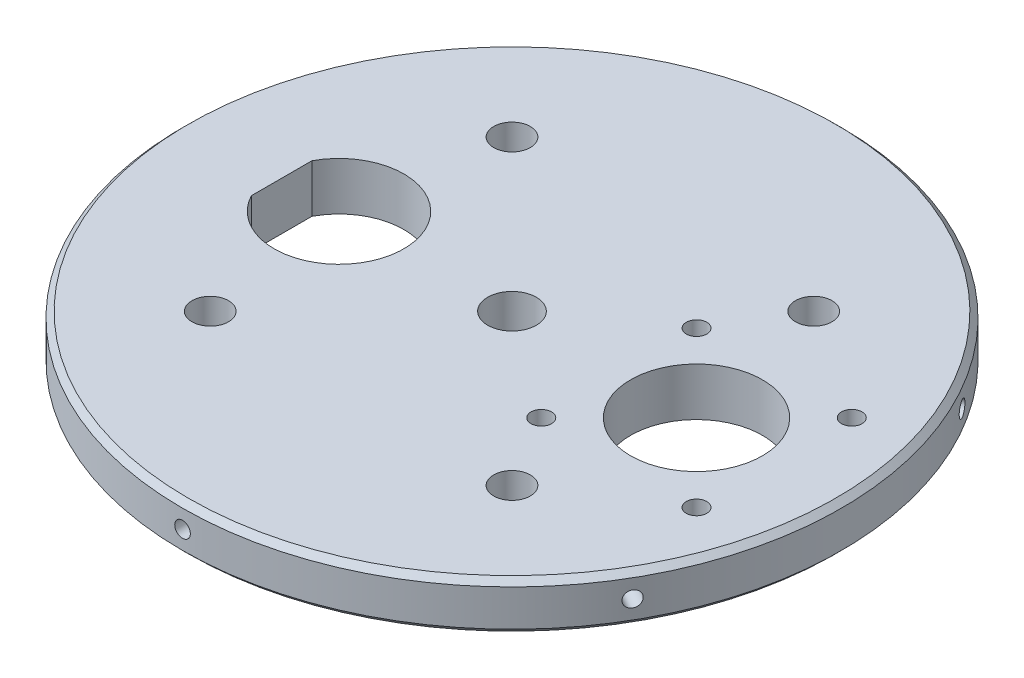
from build123d import *

# Parameters (mm, degrees)
SKETCH2_R           = 57.15
BOSS_EXTRUDE1_DEPTH = 8.35
CUT_EXTRUDE1_REACH  = 10.35
SKETCH6_R           = 3.175
SKETCH7_R           = 11.43
SKETCH7_R_2         = 1.778
CUT_EXTRUDE2_DEPTH  = 9.35
SKETCH8_R           = 4.2164
CUT_EXTRUDE3_DEPTH  = 9.35
CHAMFER1_SIZE       = 1
CIRPATTERN1_COUNT   = 6


with BuildPart() as part:
    # Sketch2 → Boss-Extrude1 (new body)
    with BuildSketch(Plane(origin=(0, 0, 0), x_dir=(1, 0, 0), z_dir=(0, 1, 0))):
        Circle(SKETCH2_R)
    extrude(amount=BOSS_EXTRUDE1_DEPTH)

    # Sketch6 → Cut-Extrude1 (cut, up to next)
    with BuildSketch(Plane(origin=(0, 8.35, 0), x_dir=(1, 0, 0), z_dir=(0, 1, 0)), mode=Mode.PRIVATE) as cut_extrude1_sk1:
        with Locations((-26.1629, -26.1629)):
            Circle(SKETCH6_R)
    cut_extrude1_tool1 = extrude(cut_extrude1_sk1.sketch, amount=-CUT_EXTRUDE1_REACH, mode=Mode.PRIVATE) & part.part
    add(cut_extrude1_tool1.solids().sort_by_distance((-26.1629, 8.35, 26.1629))[0], mode=Mode.SUBTRACT)
    # Sketch6 → Cut-Extrude1 (cut, up to next)
    with BuildSketch(Plane(origin=(0, 8.35, 0), x_dir=(1, 0, 0), z_dir=(0, 1, 0)), mode=Mode.PRIVATE) as cut_extrude1_sk2:
        with Locations((26.1629, -26.1629)):
            Circle(SKETCH6_R)
    cut_extrude1_tool2 = extrude(cut_extrude1_sk2.sketch, amount=-CUT_EXTRUDE1_REACH, mode=Mode.PRIVATE) & part.part
    add(cut_extrude1_tool2.solids().sort_by_distance((26.1629, 8.35, 26.1629))[0], mode=Mode.SUBTRACT)
    # Sketch6 → Cut-Extrude1 (cut, up to next)
    with BuildSketch(Plane(origin=(0, 8.35, 0), x_dir=(1, 0, 0), z_dir=(0, 1, 0)), mode=Mode.PRIVATE) as cut_extrude1_sk3:
        with Locations((-26.1629, 26.163103615)):
            Circle(SKETCH6_R)
    cut_extrude1_tool3 = extrude(cut_extrude1_sk3.sketch, amount=-CUT_EXTRUDE1_REACH, mode=Mode.PRIVATE) & part.part
    add(cut_extrude1_tool3.solids().sort_by_distance((-26.1629, 8.35, -26.163104))[0], mode=Mode.SUBTRACT)
    # Sketch6 → Cut-Extrude1 (cut, up to next)
    with BuildSketch(Plane(origin=(0, 8.35, 0), x_dir=(1, 0, 0), z_dir=(0, 1, 0)), mode=Mode.PRIVATE) as cut_extrude1_sk4:
        with Locations((26.1629, 26.163103615)):
            Circle(SKETCH6_R)
    cut_extrude1_tool4 = extrude(cut_extrude1_sk4.sketch, amount=-CUT_EXTRUDE1_REACH, mode=Mode.PRIVATE) & part.part
    add(cut_extrude1_tool4.solids().sort_by_distance((26.1629, 8.35, -26.163104))[0], mode=Mode.SUBTRACT)

    # Sketch7 → Cut-Extrude2 (cut, through all)
    with BuildSketch(Plane(origin=(0, 8.35, 0), x_dir=(1, 0, 0), z_dir=(0, 1, 0))):
        with Locations((32, 0)):
            Circle(SKETCH7_R)
        with Locations((18.54, -13.464)):
            Circle(SKETCH7_R_2)
        with Locations((18.54, 13.46)):
            Circle(SKETCH7_R_2)
        with Locations((45.46, 13.46)):
            Circle(SKETCH7_R_2)
        with Locations((45.46, -13.464)):
            Circle(SKETCH7_R_2)
    extrude(amount=-CUT_EXTRUDE2_DEPTH, mode=Mode.SUBTRACT)

    # Sketch8 → Cut-Extrude3 (cut, through all)
    with BuildSketch(Plane(origin=(0, 8.35, 0), x_dir=(1, 0, 0), z_dir=(0, 1, 0))):
        Circle(SKETCH8_R)
        with BuildLine():
            Line((-39.95, 5.249761899), (-39.95, -5.249761899))
            ThreePointArc((-39.95, -5.249761899), (-18.75, 0), (-39.95, 5.249761899))
        make_face()
    extrude(amount=-CUT_EXTRUDE3_DEPTH, mode=Mode.SUBTRACT)

    # Chamfer1
    chamfer1_edges = [part.edges().sort_by_distance(p)[0] for p in [
        (-57.15, 0, 0),
        (-57.15, 8.35, 0),
    ]]
    chamfer(chamfer1_edges, length=CHAMFER1_SIZE)

    # Sketch11 → #6-32 Tapped Hole1 (revolve, cut)
    with BuildSketch(Plane(origin=(0, 4.175, 57.15), x_dir=(0, -1, 0), z_dir=(1, 0, 0))):
        Polygon((0, 0), (0, 13.81269403), (1.35255, 13), (1.35255, 0), align=None)
    f_6_32_tapped_hole1 = revolve(axis=Axis((0, 4.175, 63.5), (0, 0, -1)), mode=Mode.SUBTRACT)

    # CirPattern1: #6-32 Tapped Hole1 ×6 about axis
    cirpattern1_axis = Axis((0, 1, 0), (0, 1, 0))
    for i in range(1, CIRPATTERN1_COUNT):
        add(f_6_32_tapped_hole1.rotate(cirpattern1_axis, i * 360 / CIRPATTERN1_COUNT), mode=Mode.SUBTRACT)


solid = part.part
